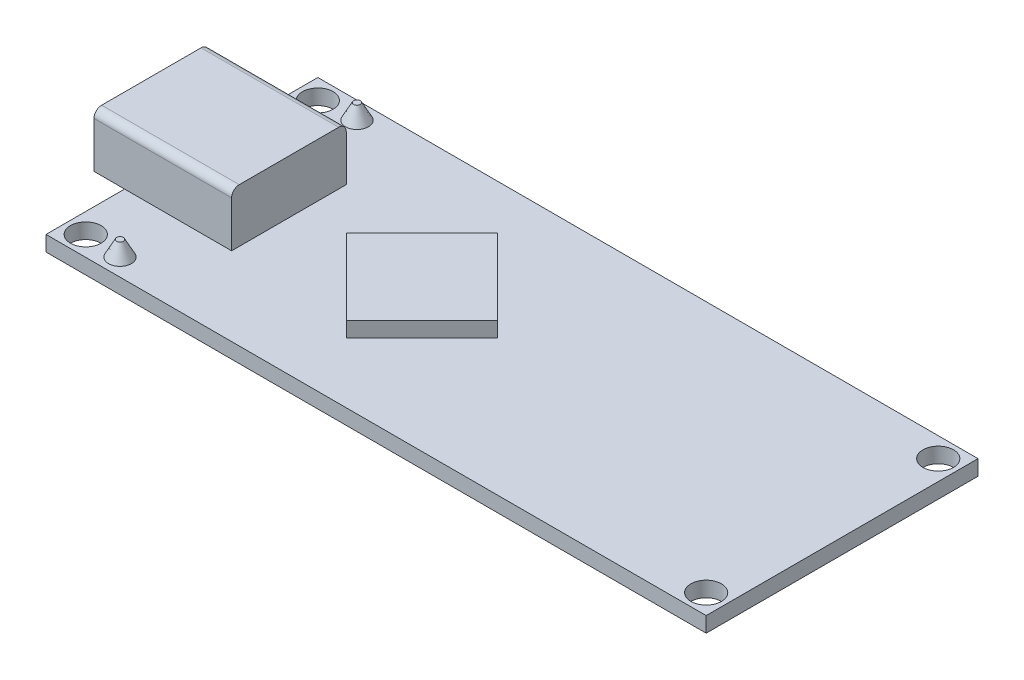
from build123d import *

# Parameters (mm, degrees)
ESBO_O1_W                          = 43.18
ESBO_O1_H                          = 17.78
RESSALTO_EXTRUS_O1_DEPTH           = 1
ESBO_O5_R                          = 0.75
RESSALTO_EXTRUS_O5_DEPTH           = 1
RESSALTO_EXTRUS_O5_DRAFT           = 28
RESSALTO_EXTRUS_O5_PROFILE_2_DEPTH = 1
RESSALTO_EXTRUS_O5_PROFILE_2_DRAFT = 28
RESSALTO_EXTRUS_O4_DEPTH           = 1
ESBO_O6_W                          = 9
ESBO_O6_H                          = 7.5
RESSALTO_EXTRUS_O6_DEPTH           = 3.5
ESBO_O7_R                          = 1
CORTE_EXTRUS_O1_DEPTH              = 26.451330024
ESBO_O8_W                          = 6.5
ESBO_O8_H                          = 2.5
ESBO_O8_W_2                        = 5
ESBO_O8_H_2                        = 1
CORTE_EXTRUS_O2_DEPTH              = 7
FILETE1_R                          = 0.5


with BuildPart() as part:
    # Esboço1 → Ressalto-extrusão1 (new body)
    with BuildSketch(Plane(origin=(0, 0, 0), x_dir=(1, 0, 0), z_dir=(0, 1, 0))):
        Rectangle(ESBO_O1_W, ESBO_O1_H)
    extrude(amount=RESSALTO_EXTRUS_O1_DEPTH)


with BuildPart() as ressalto_extrus_o5_tool:
    # Esboço5 → Ressalto-extrusão5 (with draft: the straight prism first)
    with BuildSketch(Plane(origin=(0, 1, 0), x_dir=(1, 0, 0), z_dir=(0, 1, 0))):
        with Locations((-17.89, 7.75)):
            Circle(ESBO_O5_R)
    extrude(amount=RESSALTO_EXTRUS_O5_DEPTH)
    # Ressalto-extrusão5: the draft: its side faces are tilted about the plane it starts from
    ressalto_extrus_o5_sides = [ressalto_extrus_o5_tool.faces().sort_by_distance(p)[0] for p in [
        (-18.64, 1.5, -7.75),
    ]]
    draft(ressalto_extrus_o5_sides, Plane(origin=(0, 1, 0), x_dir=(1, 0, 0), z_dir=(0, 1, 0)), RESSALTO_EXTRUS_O5_DRAFT)


with BuildPart() as part_1:
    add(part.part)

    # Ressalto-extrusão5: add ressalto_extrus_o5_tool
    add(ressalto_extrus_o5_tool.part)


with BuildPart() as ressalto_extrus_o5_profile_2_tool:
    # Esboço5 → Ressalto-extrusão5 profile 2 (with draft: the straight prism first)
    with BuildSketch(Plane(origin=(0, 1, 0), x_dir=(1, 0, 0), z_dir=(0, 1, 0))):
        with Locations((-17.89, -7.75)):
            Circle(ESBO_O5_R)
    extrude(amount=RESSALTO_EXTRUS_O5_PROFILE_2_DEPTH)
    # Ressalto-extrusão5 profile 2: the draft: its side faces are tilted about the plane it starts from
    ressalto_extrus_o5_profile_2_sides = [ressalto_extrus_o5_profile_2_tool.faces().sort_by_distance(p)[0] for p in [
        (-18.64, 1.5, 7.75),
    ]]
    draft(ressalto_extrus_o5_profile_2_sides, Plane(origin=(0, 1, 0), x_dir=(1, 0, 0), z_dir=(0, 1, 0)), RESSALTO_EXTRUS_O5_PROFILE_2_DRAFT)


with BuildPart() as part_2:
    add(part_1.part)

    # Ressalto-extrusão5 profile 2: add ressalto_extrus_o5_profile_2_tool
    add(ressalto_extrus_o5_profile_2_tool.part)

    # Esboço4 → Ressalto-extrusão4 (add)
    with BuildSketch(Plane(origin=(0, 1, 0), x_dir=(1, 0, 0), z_dir=(0, 1, 0))):
        Polygon((-10.839747468, 0), (-5.89, 4.949747468), (-0.940252532, 0), (-5.89, -4.949747468), align=None)
    extrude(amount=RESSALTO_EXTRUS_O4_DEPTH)

    # Esboço6 → Ressalto-extrusão6 (add)
    with BuildSketch(Plane(origin=(0, 1, 0), x_dir=(1, 0, 0), z_dir=(0, 1, 0))):
        with Locations((-19.09, 0)):
            Rectangle(ESBO_O6_W, ESBO_O6_H)
    extrude(amount=RESSALTO_EXTRUS_O6_DEPTH)

    # Esboço7 → Corte-extrusão1 (cut, through all)
    with BuildSketch(Plane(origin=(0, 1, 0), x_dir=(1, 0, 0), z_dir=(0, 1, 0))):
        with Locations((-20.29, 7.59)):
            Circle(ESBO_O7_R)
        with Locations((-20.29, -7.59)):
            Circle(ESBO_O7_R)
        with Locations((20.29, -7.59)):
            Circle(ESBO_O7_R)
        with Locations((20.29, 7.59)):
            Circle(ESBO_O7_R)
    extrude(amount=-CORTE_EXTRUS_O1_DEPTH, mode=Mode.SUBTRACT)

    # Esboço8 → Corte-extrusão2 (cut)
    with BuildSketch(Plane.ZY.offset(23.59)):
        with Locations((0, 2.75)):
            Rectangle(ESBO_O8_W, ESBO_O8_H)
        with Locations((0, 2.75)):
            Rectangle(ESBO_O8_W_2, ESBO_O8_H_2, mode=Mode.SUBTRACT)
    extrude(amount=-CORTE_EXTRUS_O2_DEPTH, mode=Mode.SUBTRACT)

    # Filete1
    filete1_edges = [part_2.edges().sort_by_distance(p)[0] for p in [
        (-19.09, 4.5, -3.75),
        (-19.09, 4.5, 3.75),
    ]]
    fillet(filete1_edges, radius=FILETE1_R)


solid = part_2.part
